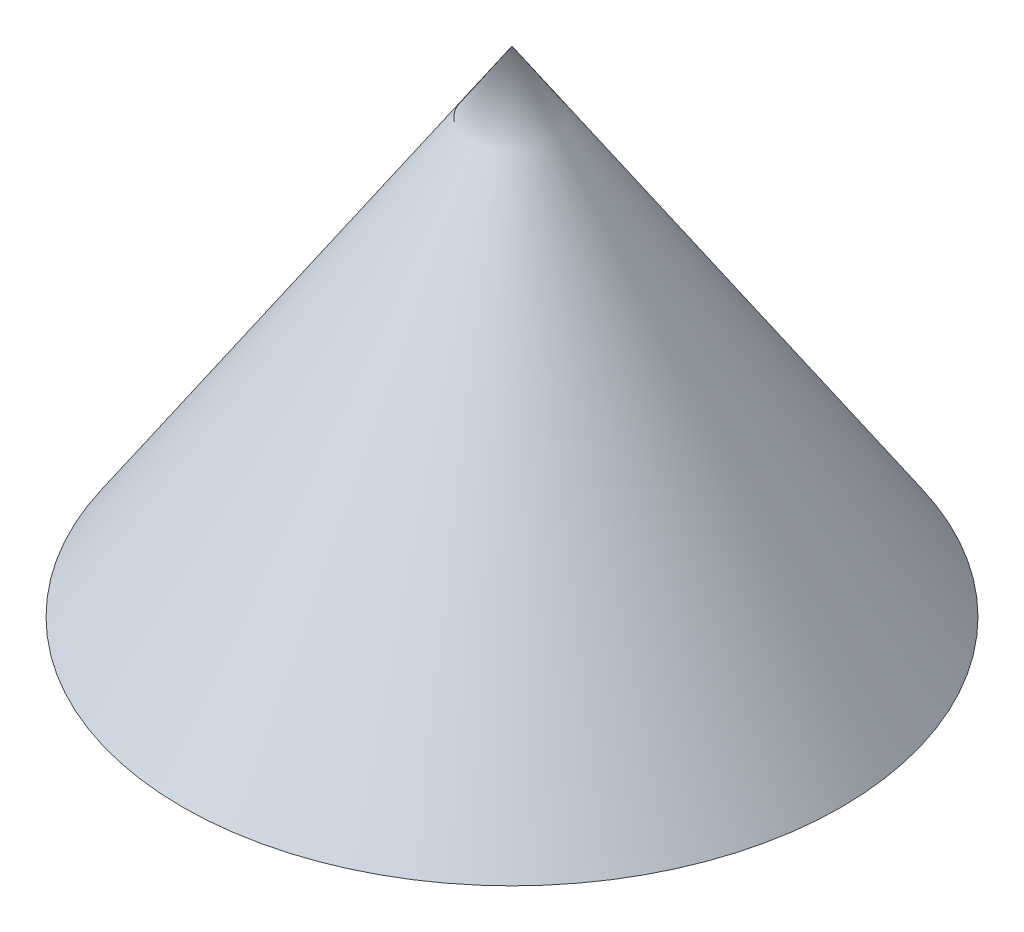
from build123d import *


with BuildPart() as part:
    # Sketch1 → Revolve1 (revolve)
    with BuildSketch(Plane.XY):
        Polygon((0, 0), (0, 105), (70, 0), align=None)
    revolve(axis=Axis((0, 0, 0), (0, 1, 0)))


solid = part.part
